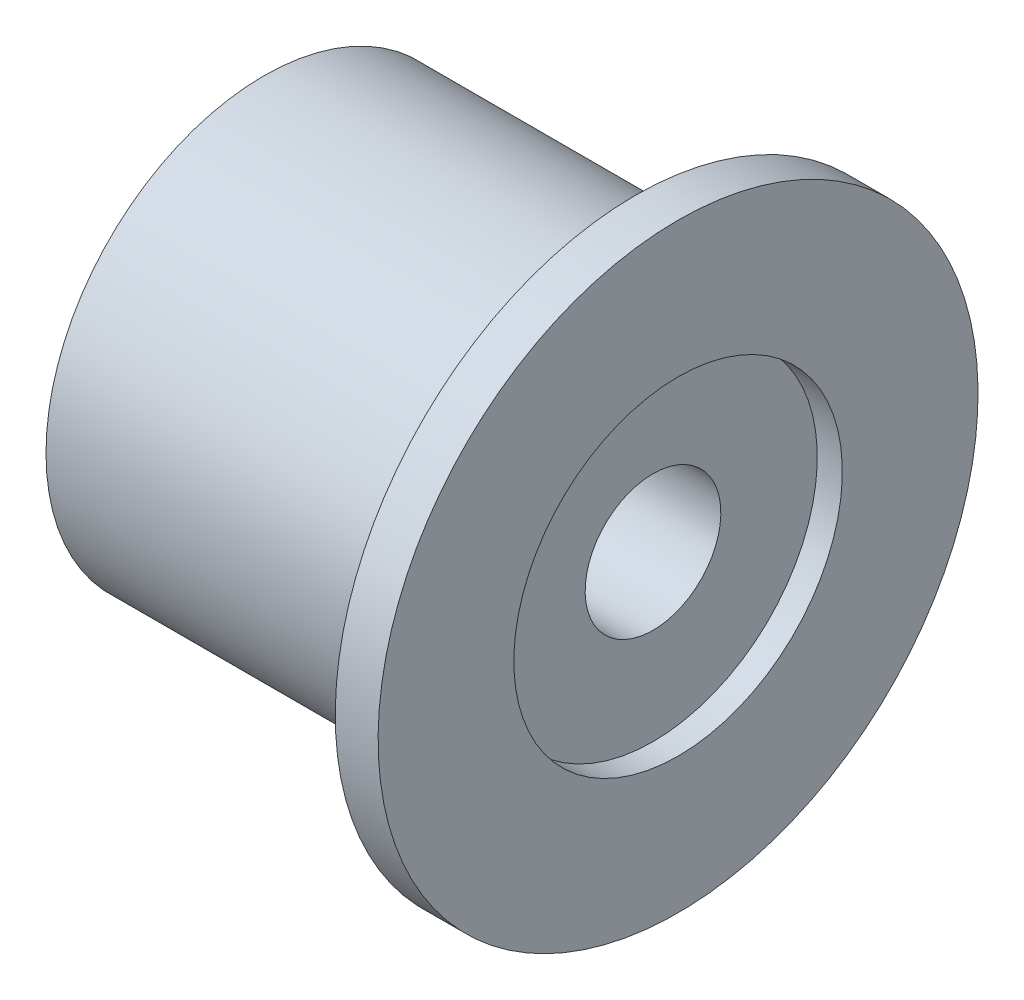
from build123d import *


with BuildPart() as part:
    # Sketch1 → Revolve1 (revolve)
    with BuildSketch(Plane.XY):
        Polygon((-15.24, 6.731), (-10.922, 2.413), (-1.4, 2.413), (-1.4, 5.842), (-0.508, 5.842), (-0.508, 10.668), (-2.032, 10.668), (-2.032, 7.747), (-15.24, 7.747), align=None)
    revolve(axis=Axis((0, 0, 0), (-1, 0, 0)))


solid = part.part
